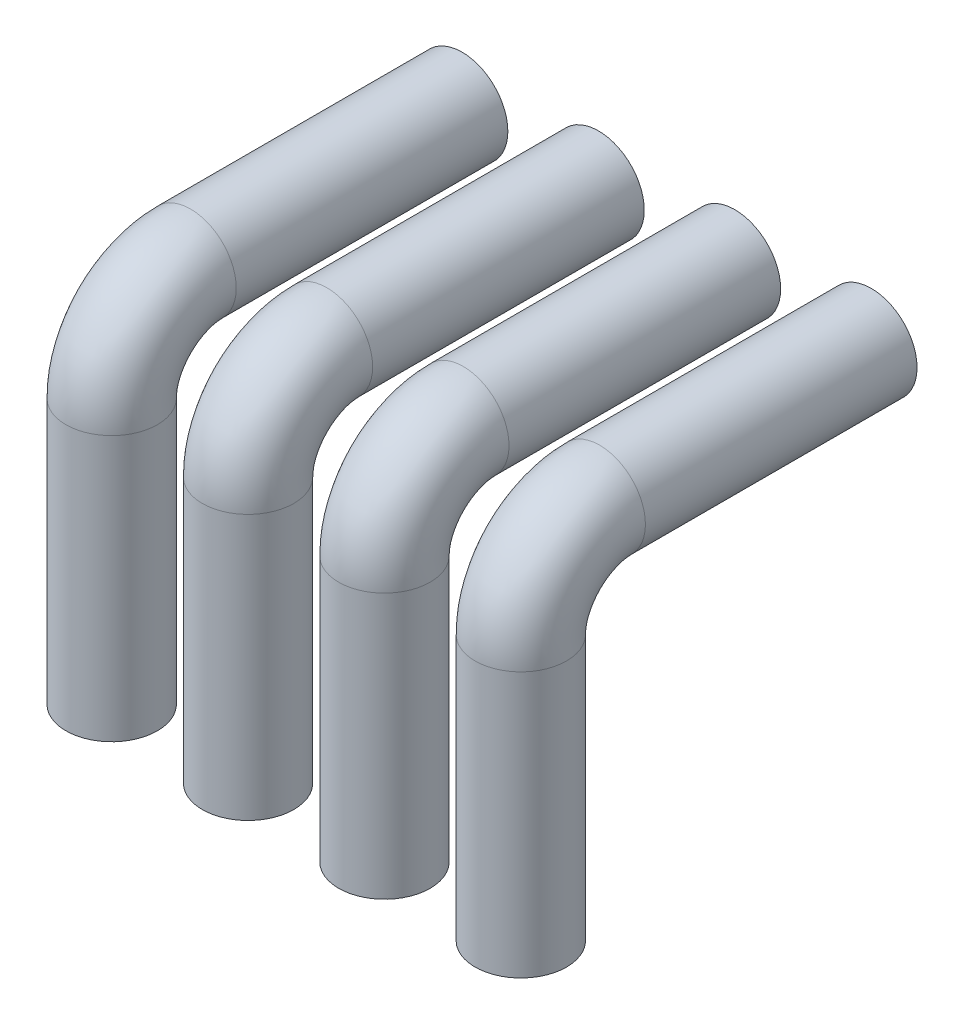
from build123d import *

# Parameters (mm, degrees)
SKETCH1_R = 6.708334263


with BuildPart() as part:
    # Sweep1: sweep along a path in Sketch2
    with BuildLine(Plane(origin=(0, 0, 0), x_dir=(0, 0, -1), z_dir=(1, 0, 0))) as sweep1_path:
        Line((0, 24.735101447), (-39.829973559, 24.735101447))
        ThreePointArc((-39.829973559, 24.735101447), (-48.003682266, 21.349440446), (-51.389343267, 13.175731739))
        Line((-51.389343267, 13.175731739), (-51.389343267, -25.700745291))
    # Sketch1 → Sweep1 (sweep)
    with BuildSketch(Plane.XY):
        with Locations((0, 24.735101447)):
            Circle(SKETCH1_R)
        with Locations((20, 24.735101447)):
            Circle(SKETCH1_R)
        with Locations((40, 24.735101447)):
            Circle(SKETCH1_R)
        with Locations((60, 24.735101447)):
            Circle(SKETCH1_R)
    sweep(path=sweep1_path.line)


solid = part.part
